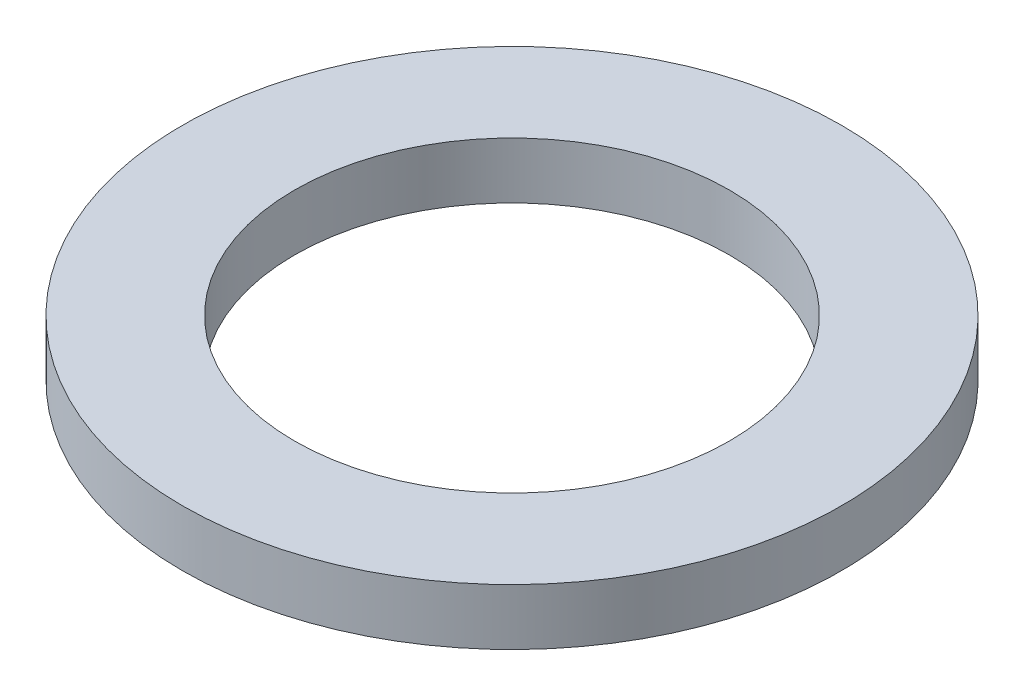
from build123d import *

# Parameters (mm, degrees)
SKETCH1_R           = 4.90855
SKETCH1_R_2         = 3.2385
BOSS_EXTRUDE1_DEPTH = 0.8382


with BuildPart() as part:
    # Sketch1 → Boss-Extrude1 (new body)
    with BuildSketch(Plane(origin=(0, 0, 0), x_dir=(1, 0, 0), z_dir=(0, 1, 0))):
        Circle(SKETCH1_R)
        Circle(SKETCH1_R_2, mode=Mode.SUBTRACT)
    extrude(amount=BOSS_EXTRUDE1_DEPTH)


solid = part.part
